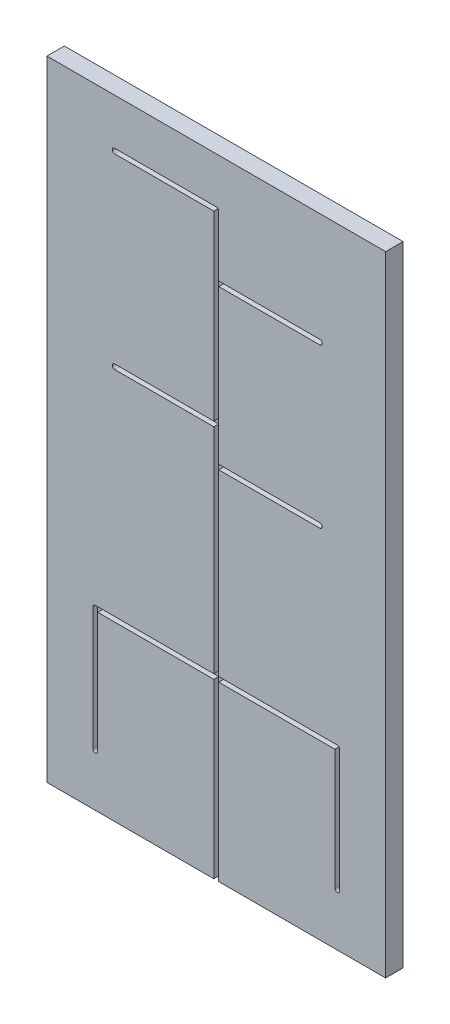
from build123d import *

# Parameters (mm, degrees)
SKICA1_W                 = 350
SKICA1_H                 = 650
P_IDAT_VYSUNUT_M2_DEPTH  = 18
VETSI_W                  = 30
VETSI_H                  = 166
VETSI_H_2                = 30
ODEBRAT_VYSUNUT_M1_DEPTH = 15
P_IDAT_VYSUNUT_M3_DEPTH  = 5


with BuildPart() as part:
    # Skica1 → Přidat vysunutím2 (new body)
    with BuildSketch(Plane.XY):
        with Locations((175, 325)):
            Rectangle(SKICA1_W, SKICA1_H)
    extrude(amount=P_IDAT_VYSUNUT_M2_DEPTH)

    # vetsi → Odebrat vysunutím1 (cut)
    with BuildSketch(Plane.XY.offset(18)):
        with BuildLine():
            Line((65, 54), (65, 166))
            Line((65, 166), (50, 166))
            ThreePointArc((50, 166), (39.393398282, 170.393398282), (35, 181))
            Line((35, 181), (35, 54))
            ThreePointArc((35, 54), (50, 39), (65, 54))
        make_face()
        with BuildLine():
            ThreePointArc((65, 181), (60.606601718, 191.606601718), (50, 196))
            ThreePointArc((50, 196), (39.393398282, 191.606601718), (35, 181))
            ThreePointArc((35, 181), (39.393398282, 170.393398282), (50, 166))
            Line((50, 166), (65, 166))
            Line((65, 166), (65, 181))
        make_face()
        with BuildLine():
            Line((160, 166), (160, 196))
            Line((160, 196), (50, 196))
            ThreePointArc((50, 196), (60.606601718, 191.606601718), (65, 181))
            Line((65, 181), (65, 166))
            Line((65, 166), (160, 166))
        make_face()
        with Locations((175, 83)):
            Rectangle(VETSI_W, VETSI_H)
        with Locations((175, 181)):
            Rectangle(VETSI_W, VETSI_H_2)
        with BuildLine():
            Line((300, 196), (190, 196))
            Line((190, 196), (190, 166))
            Line((190, 166), (285, 166))
            Line((285, 166), (285, 181))
            ThreePointArc((285, 181), (289.393398282, 191.606601718), (300, 196))
        make_face()
        with BuildLine():
            ThreePointArc((315, 181), (310.606601718, 191.606601718), (300, 196))
            ThreePointArc((300, 196), (289.393398282, 191.606601718), (285, 181))
            Line((285, 181), (285, 166))
            Line((285, 166), (300, 166))
            ThreePointArc((300, 166), (310.606601718, 170.393398282), (315, 181))
        make_face()
        with BuildLine():
            Line((300, 166), (285, 166))
            Line((285, 166), (285, 54))
            ThreePointArc((285, 54), (300, 39), (315, 54))
            Line((315, 54), (315, 181))
            ThreePointArc((315, 181), (310.606601718, 170.393398282), (300, 166))
        make_face()
        with BuildLine():
            Line((190, 196), (190, 356))
            Line((190, 356), (175, 356))
            ThreePointArc((175, 356), (164.393398282, 360.393398282), (160, 371))
            Line((160, 371), (160, 196))
            Line((160, 196), (190, 196))
        make_face()
        with BuildLine():
            Line((282, 386), (190, 386))
            Line((190, 386), (190, 356))
            Line((190, 356), (282, 356))
            ThreePointArc((282, 356), (297, 371), (282, 386))
        make_face()
        with BuildLine():
            Line((190, 356), (190, 386))
            Line((190, 386), (175, 386))
            ThreePointArc((175, 386), (164.393398282, 381.606601718), (160, 371))
            ThreePointArc((160, 371), (164.393398282, 360.393398282), (175, 356))
            Line((175, 356), (190, 356))
        make_face()
        with BuildLine():
            Line((190, 386), (190, 407.000000086))
            ThreePointArc((190, 407.000000086), (185.606601748, 396.393398312), (175, 392))
            Line((175, 392), (160, 392))
            Line((160, 392), (160, 371))
            ThreePointArc((160, 371), (164.393398282, 381.606601718), (175, 386))
            Line((175, 386), (190, 386))
        make_face()
        with BuildLine():
            ThreePointArc((175, 392), (185.606601748, 396.393398312), (190, 407.000000086))
            ThreePointArc((190, 407.000000086), (185.606601688, 417.606601748), (175, 422))
            Line((175, 422), (160, 422))
            Line((160, 422), (160, 392))
            Line((160, 392), (175, 392))
        make_face()
        with BuildLine():
            Line((160, 392), (160, 422))
            Line((160, 422), (70, 422))
            ThreePointArc((70, 422), (55, 407), (70, 392))
            Line((70, 392), (160, 392))
        make_face()
        with BuildLine():
            Line((190, 407.000000086), (190, 520))
            Line((190, 520), (175, 520))
            ThreePointArc((175, 520), (164.393398282, 524.393398282), (160, 535))
            Line((160, 535), (160, 422))
            Line((160, 422), (175, 422))
            ThreePointArc((175, 422), (185.606601688, 417.606601748), (190, 407.000000086))
        make_face()
        with BuildLine():
            Line((190, 520), (190, 550))
            Line((190, 550), (175, 550))
            ThreePointArc((175, 550), (164.393398282, 545.606601718), (160, 535))
            ThreePointArc((160, 535), (164.393398282, 524.393398282), (175, 520))
            Line((175, 520), (190, 520))
        make_face()
        with BuildLine():
            Line((282, 550), (190, 550))
            Line((190, 550), (190, 520))
            Line((190, 520), (282, 520))
            ThreePointArc((282, 520), (297, 535), (282, 550))
        make_face()
        with BuildLine():
            Line((190, 550), (190, 600))
            ThreePointArc((190, 600), (185.606601718, 589.393398282), (175, 585))
            Line((175, 585), (160, 585))
            Line((160, 585), (160, 535))
            ThreePointArc((160, 535), (164.393398282, 545.606601718), (175, 550))
            Line((175, 550), (190, 550))
        make_face()
        with BuildLine():
            ThreePointArc((175, 585), (185.606601718, 589.393398282), (190, 600))
            ThreePointArc((190, 600), (185.606601718, 610.606601718), (175, 615))
            ThreePointArc((175, 615), (164.393398282, 610.606601718), (160, 600))
            Line((160, 600), (160, 585))
            Line((160, 585), (175, 585))
        make_face()
        with BuildLine():
            ThreePointArc((160, 600), (164.393398282, 610.606601718), (175, 615))
            Line((175, 615), (70, 615))
            ThreePointArc((70, 615), (55, 600), (70, 585))
            Line((70, 585), (160, 585))
            Line((160, 585), (160, 600))
        make_face()
    extrude(amount=-ODEBRAT_VYSUNUT_M1_DEPTH, mode=Mode.SUBTRACT)

    # mensi → Přidat vysunutím3 (add)
    with BuildSketch(Plane.XY.offset(18)):
        with BuildLine():
            ThreePointArc((175, 602.5), (176.767766953, 601.767766953), (177.5, 600))
            Line((177.5, 600), (177.5, 537.5))
            Line((177.5, 537.5), (282, 537.5))
            ThreePointArc((282, 537.5), (284.5, 535), (282, 532.5))
            Line((282, 532.5), (177.5, 532.5))
            Line((177.5, 532.5), (177.5, 406.999999943))
            Line((177.5, 406.999999943), (177.5, 373.5))
            Line((177.5, 373.5), (282, 373.5))
            ThreePointArc((282, 373.5), (284.5, 371), (282, 368.5))
            Line((282, 368.5), (177.5, 368.5))
            Line((177.5, 368.5), (177.5, 183.5))
            Line((177.5, 183.5), (300, 183.5))
            ThreePointArc((300, 183.5), (301.767766953, 182.767766953), (302.5, 181))
            Line((302.5, 181), (302.5, 54))
            ThreePointArc((302.5, 54), (300, 51.5), (297.5, 54))
            Line((297.5, 54), (297.5, 178.5))
            Line((297.5, 178.5), (177.5, 178.5))
            Line((177.5, 178.5), (177.5, 0))
            Line((177.5, 0), (350, 0))
            Line((350, 0), (350, 650))
            Line((350, 650), (0, 650))
            Line((0, 650), (0, 0))
            Line((0, 0), (172.5, 0))
            Line((172.5, 0), (172.5, 178.5))
            Line((172.5, 178.5), (52.5, 178.5))
            Line((52.5, 178.5), (52.5, 54))
            ThreePointArc((52.5, 54), (50, 51.5), (47.5, 54))
            Line((47.5, 54), (47.5, 181))
            ThreePointArc((47.5, 181), (48.232233047, 182.767766953), (50, 183.5))
            Line((50, 183.5), (172.5, 183.5))
            Line((172.5, 183.5), (172.5, 371))
            Line((172.5, 371), (172.5, 404.5))
            Line((172.5, 404.5), (70, 404.5))
            ThreePointArc((70, 404.5), (67.5, 407), (70, 409.5))
            Line((70, 409.5), (172.5, 409.5))
            Line((172.5, 409.5), (172.5, 535))
            Line((172.5, 535), (172.5, 597.5))
            Line((172.5, 597.5), (70, 597.5))
            ThreePointArc((70, 597.5), (67.5, 600), (70, 602.5))
            Line((70, 602.5), (175, 602.5))
        make_face()
    extrude(amount=-P_IDAT_VYSUNUT_M3_DEPTH)


solid = part.part
